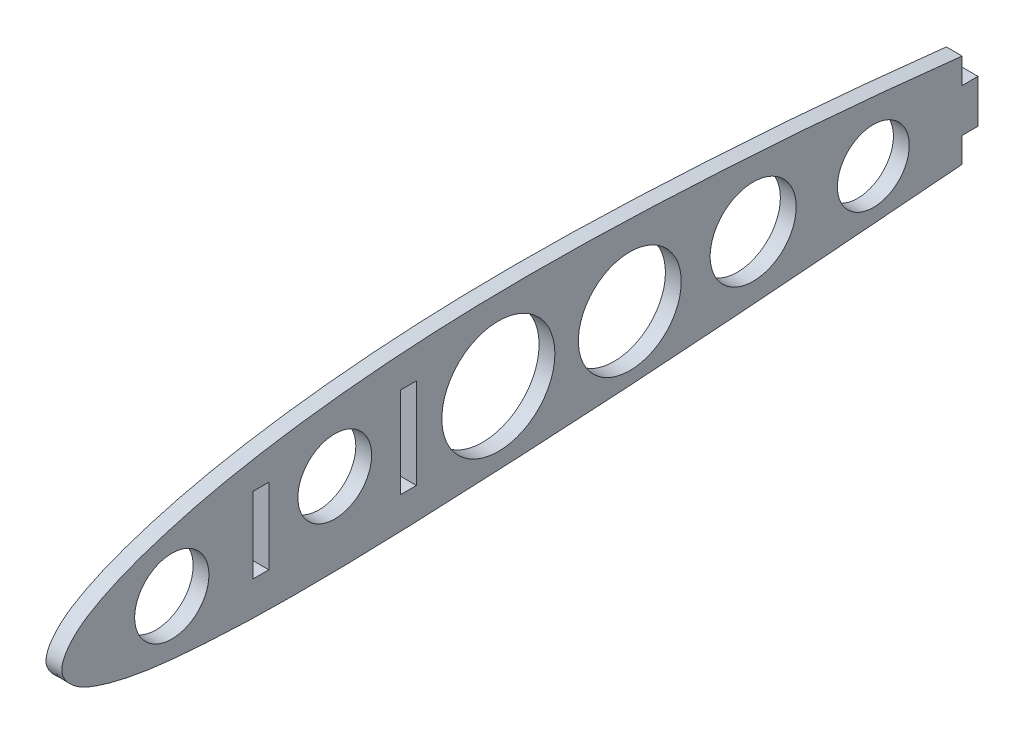
from build123d import *

# Parameters (mm, degrees)
BOSS_EXTRUDE1_DEPTH = 3
SKETCH2_W           = 74.841252749
SKETCH2_H           = 66.315034081
CUT_EXTRUDE1_DEPTH  = 3
SKETCH3_R           = 7
SKETCH3_W           = 3
SKETCH3_H           = 14.395558413
SKETCH3_H_2         = 17.195938277
CUT_EXTRUDE2_DEPTH  = 3
SKETCH4_R           = 7.044857873
SKETCH4_R_2         = 10.724515653
SKETCH4_R_3         = 9.758763148
SKETCH4_R_4         = 8.161038764
SKETCH4_R_5         = 6.816862921
CUT_EXTRUDE3_DEPTH  = 10
SKETCH5_W           = 3
SKETCH5_H           = 9.253846866
SKETCH5_H_2         = 11.213203877
CUT_EXTRUDE4_DEPTH  = 10


with BuildPart() as part:
    # Sketch1 → Boss-Extrude1 (new body)
    with BuildSketch(Plane(origin=(0, 0, 0), x_dir=(0, 0, -1), z_dir=(1, 0, 0))):
        with BuildLine():
            Line((268.808883507, 35.038681193), (271.10657713, 35.24476335))
            Line((271.10657713, 35.24476335), (268.796840467, 35.672508379))
            add(Edge.make_bspline(
                [(268.796840467, 35.672508379), (264.720288829, 36.427453618), (256.577892296, 37.935361291), (240.28448709, 40.671091197), (219.915007865, 43.658269922), (195.46608359, 46.68595214), (171.032194679, 49.134081766), (146.602549735, 50.802398651), (122.191533804, 51.782693653), (101.842925907, 51.640505529), (85.596577962, 50.658463208), (73.410994215, 49.440273566), (61.220938789, 47.646220222), (51.087627717, 45.52966298), (43.021363917, 43.199653451), (36.912240055, 41.104592505), (31.748246005, 38.700659835), (27.309151138, 35.820770177), (23.483631637, 30.91358531), (27.633420943, 26.742996915), (32.078400112, 24.889323349), (37.291241206, 23.516154351), (43.437765903, 22.577358869), (51.594932212, 21.831527037), (61.768868064, 21.331485866), (73.974609723, 21.285416293), (86.165628181, 21.555790003), (102.412296423, 22.223384598), (122.718782884, 23.255037318), (147.076924358, 24.841775407), (171.421597621, 26.76515465), (195.769310915, 28.746177015), (220.120839871, 30.74582063), (240.404536762, 32.546747402), (256.637275317, 33.946998971), (264.751495035, 34.674770459), (268.808883507, 35.038681193)],
                knots=[0, 0, 0, 0, 0.02501249, 0.049959286, 0.099672925, 0.14920632, 0.198581097, 0.24780517, 0.296916575, 0.345952722, 0.370491626, 0.395091204, 0.419814796, 0.444798575, 0.457489819, 0.470406405, 0.483879409, 0.49126412, 0.503458853, 0.513609129, 0.520450991, 0.533235388, 0.545691039, 0.558031884, 0.582609167, 0.607134742, 0.63165208, 0.656174272, 0.705233949, 0.754320379, 0.803437364, 0.852566096, 0.901700994, 0.950848809, 0.975422717, 1, 1, 1, 1], degree=3))
        make_face()
    extrude(amount=BOSS_EXTRUDE1_DEPTH)

    # Sketch2 → Cut-Extrude1 (cut)
    with BuildSketch(Plane(origin=(3, 0, 0), x_dir=(0, 0, -1), z_dir=(1, 0, 0))):
        with Locations((236.270626375, 36.221594286)):
            Rectangle(SKETCH2_W, SKETCH2_H)
    extrude(amount=-CUT_EXTRUDE1_DEPTH, mode=Mode.SUBTRACT)

    # Sketch3 → Cut-Extrude2 (cut)
    with BuildSketch(Plane(origin=(3, 0, 0), x_dir=(0, 0, -1), z_dir=(1, 0, 0))):
        with Locations((76.79, 36.990255543)):
            Circle(SKETCH3_R)
        with Locations((62.79, 35.096446052)):
            Rectangle(SKETCH3_W, SKETCH3_H)
        with Locations((90.79, 36.353674268)):
            Rectangle(SKETCH3_W, SKETCH3_H_2)
    extrude(amount=-CUT_EXTRUDE2_DEPTH, mode=Mode.SUBTRACT)

    # Sketch4 → Cut-Extrude3 (cut)
    with BuildSketch(Plane(origin=(3, 0, 0), x_dir=(0, 0, -1), z_dir=(1, 0, 0))):
        with Locations((45.873028296, 32.769995664)):
            Circle(SKETCH4_R)
        with Locations((107.839865259, 36.289099985)):
            Circle(SKETCH4_R_2)
        with Locations((132.77960458, 36.13609545)):
            Circle(SKETCH4_R_3)
        with Locations((156.189298544, 37.513136271)):
            Circle(SKETCH4_R_4)
        with Locations((178.986974365, 36.901118128)):
            Circle(SKETCH4_R_5)
    extrude(amount=-CUT_EXTRUDE3_DEPTH, mode=Mode.SUBTRACT)

    # Sketch5 → Cut-Extrude4 (cut)
    with BuildSketch(Plane(origin=(3, 0, 0), x_dir=(0, 0, -1), z_dir=(1, 0, 0))):
        with Locations((197.35, 46.331989417)):
            Rectangle(SKETCH5_W, SKETCH5_H)
        with Locations((197.35, 27.894636637)):
            Rectangle(SKETCH5_W, SKETCH5_H_2)
    extrude(amount=-CUT_EXTRUDE4_DEPTH, mode=Mode.SUBTRACT)


solid = part.part
